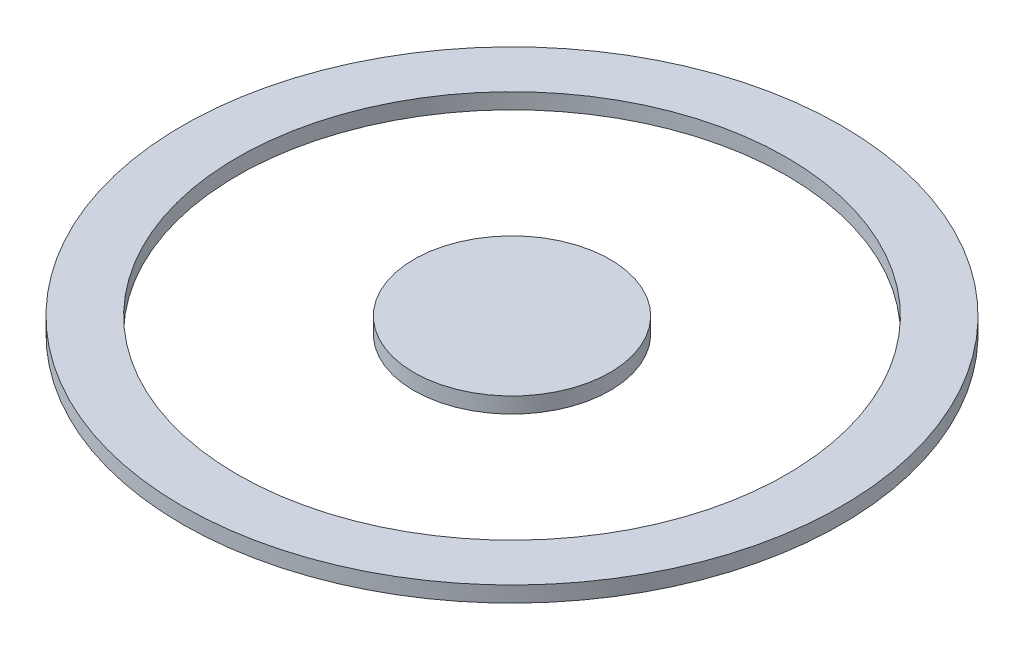
from build123d import *

# Parameters (mm, degrees)
SKETCH1_R           = 42
BOSS_EXTRUDE1_DEPTH = 2
SKETCH2_R           = 35
SKETCH2_R_2         = 12.5
CUT_EXTRUDE1_DEPTH  = 2


with BuildPart() as part:
    # Sketch1 → Boss-Extrude1 (new body)
    with BuildSketch(Plane(origin=(0, 0, 0), x_dir=(1, 0, 0), z_dir=(0, 1, 0))):
        Circle(SKETCH1_R)
    extrude(amount=BOSS_EXTRUDE1_DEPTH)

    # Sketch2 → Cut-Extrude1 (cut)
    with BuildSketch(Plane(origin=(0, 2, 0), x_dir=(1, 0, 0), z_dir=(0, 1, 0))):
        Circle(SKETCH2_R)
        Circle(SKETCH2_R_2, mode=Mode.SUBTRACT)
    extrude(amount=-CUT_EXTRUDE1_DEPTH, mode=Mode.SUBTRACT)


solid = part.part
